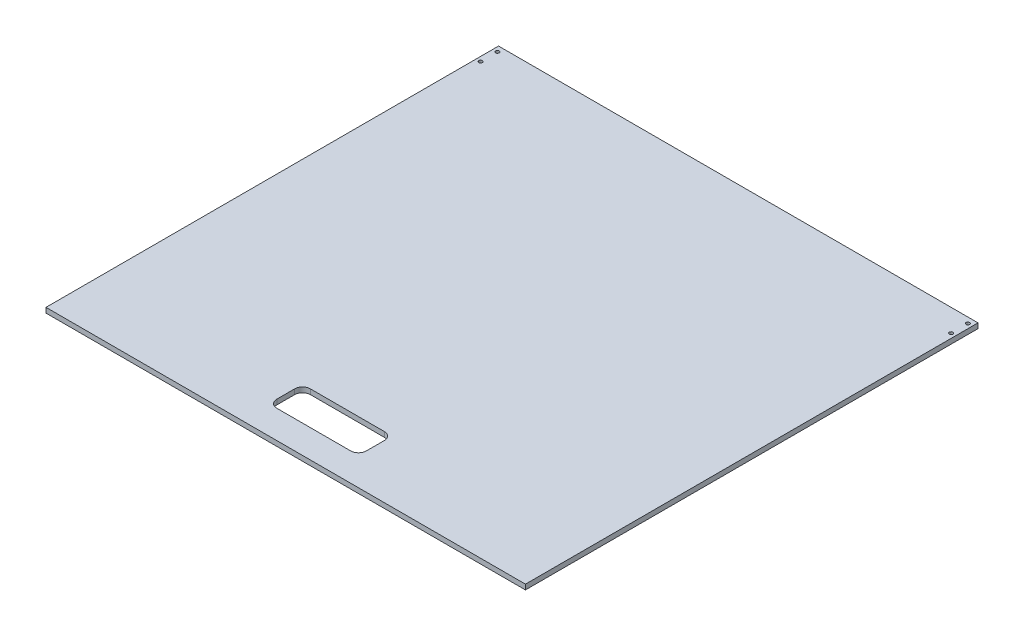
from build123d import *

# Parameters (mm, degrees)
SKETCH1_W           = 428
SKETCH1_H           = 404
BOSS_EXTRUDE1_DEPTH = 4.5
SKETCH2_R           = 1.6
CUT_EXTRUDE1_DEPTH  = 5.5
CUT_EXTRUDE2_DEPTH  = 5.5


with BuildPart() as part:
    # Sketch1 → Boss-Extrude1 (new body)
    with BuildSketch(Plane(origin=(0, 0, 0), x_dir=(1, 0, 0), z_dir=(0, 1, 0))):
        Rectangle(SKETCH1_W, SKETCH1_H)
    extrude(amount=BOSS_EXTRUDE1_DEPTH)

    # Sketch2 → Cut-Extrude1 (cut, through all)
    with BuildSketch(Plane.XZ):
        with Locations((210, -182)):
            Circle(SKETCH2_R)
        with Locations((210, -197)):
            Circle(SKETCH2_R)
    cut_extrude1 = extrude(amount=-CUT_EXTRUDE1_DEPTH, mode=Mode.SUBTRACT)

    # Mirror1: Cut-Extrude1 across plane
    add(cut_extrude1.mirror(Plane(origin=(0, 0, 0), x_dir=(0, 0, 1), z_dir=(1, 0, 0))), mode=Mode.SUBTRACT)

    # Sketch3 → Cut-Extrude2 (cut, through all)
    with BuildSketch(Plane(origin=(0, 4.5, 0), x_dir=(1, 0, 0), z_dir=(0, 1, 0))):
        with BuildLine():
            Line((-33, -177), (33, -177))
            ThreePointArc((33, -177), (37.949747468, -174.949747468), (40, -170))
            Line((40, -170), (40, -154))
            ThreePointArc((40, -154), (37.949747468, -149.050252532), (33, -147))
            Line((33, -147), (-33, -147))
            ThreePointArc((-33, -147), (-37.949747468, -149.050252532), (-40, -154))
            Line((-40, -154), (-40, -170))
            ThreePointArc((-40, -170), (-37.949747468, -174.949747468), (-33, -177))
        make_face()
    extrude(amount=-CUT_EXTRUDE2_DEPTH, mode=Mode.SUBTRACT)


solid = part.part
